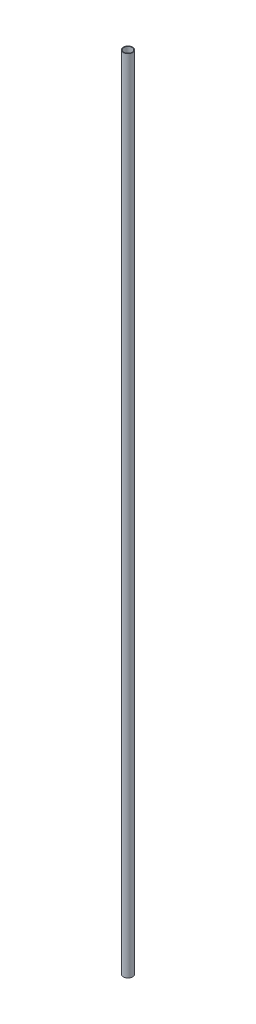
from build123d import *

# Parameters (mm, degrees)
SKETCH1_R           = 0.73533
SKETCH1_R_2         = 0.64516
BOSS_EXTRUDE1_DEPTH = 125
SKETCH2_W           = 1
SKETCH2_H           = 0.344184039
CUT_EXTRUDE1_DEPTH  = 10


with BuildPart() as part:
    # Sketch1 → Boss-Extrude1 (new body)
    with BuildSketch(Plane(origin=(0, 0, 0), x_dir=(1, 0, 0), z_dir=(0, 1, 0))):
        Circle(SKETCH1_R)
        Circle(SKETCH1_R_2, mode=Mode.SUBTRACT)
    extrude(amount=BOSS_EXTRUDE1_DEPTH)

    # Sketch2 → Cut-Extrude1 (cut)
    with BuildSketch(Plane.XZ):
        with Locations((0, -0.563237981)):
            Rectangle(SKETCH2_W, SKETCH2_H)
    extrude(amount=-CUT_EXTRUDE1_DEPTH, mode=Mode.SUBTRACT)


solid = part.part
